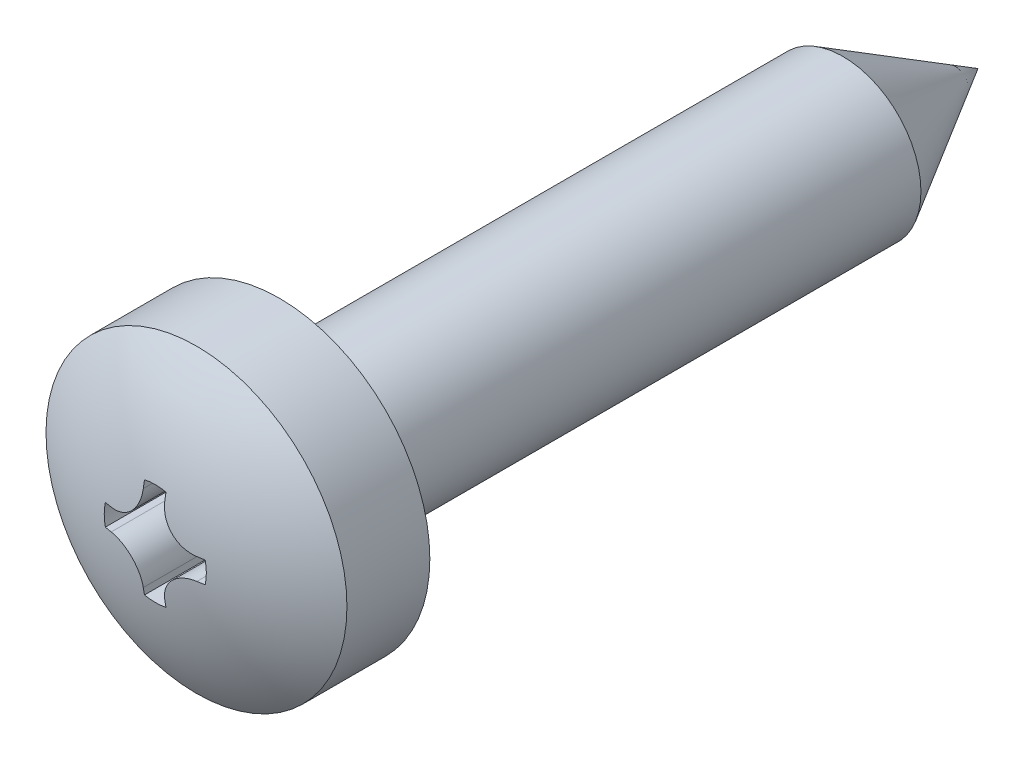
from build123d import *

# Parameters (mm, degrees)
CUT_EXTRUDE_2_DEPTH = 1.2
FILLET_1_R          = 0.1


with BuildPart() as part:
    # 草图8 → Revolve 1380 (revolve)
    with BuildSketch(Plane(origin=(0, 0, 0), x_dir=(0, 0, -1), z_dir=(1, 0, 0))):
        with BuildLine():
            Line((0, 0), (-15.4, 0))
            ThreePointArc((-15.4, 0), (-15.180811394, 1.464186604), (-14.542463035, 2.8))
            Line((-14.542463035, 2.8), (-13, 2.8))
            Line((-13, 2.8), (-13, 1.45))
            Line((-13, 1.45), (-2.511473671, 1.45))
            Line((-2.511473671, 1.45), (0, 0))
        make_face()
    revolve(axis=Axis((0, 0, 11.71), (0, 0, -1)))

    # 草图7 → 切除-拉伸2 (cut)
    with BuildSketch(Plane.XY.offset(15.4)):
        with BuildLine():
            Line((0.2, 0.928708781), (0.2, 0.797500009))
            ThreePointArc((0.2, 0.797500009), (0.375003701, 0.375003701), (0.797500009, 0.2))
            Line((0.797500009, 0.2), (0.928708781, 0.2))
            ThreePointArc((0.928708781, 0.2), (0.95, 0), (0.928708781, -0.2))
            Line((0.928708781, -0.2), (0.797500009, -0.2))
            ThreePointArc((0.797500009, -0.2), (0.375003701, -0.375003701), (0.2, -0.797500009))
            Line((0.2, -0.797500009), (0.2, -0.928708781))
            ThreePointArc((0.2, -0.928708781), (0, -0.95), (-0.2, -0.928708781))
            Line((-0.2, -0.928708781), (-0.2, -0.797500009))
            ThreePointArc((-0.2, -0.797500009), (-0.375003701, -0.375003701), (-0.797500009, -0.2))
            Line((-0.797500009, -0.2), (-0.928708781, -0.2))
            ThreePointArc((-0.928708781, -0.2), (-0.95, 0), (-0.928708781, 0.2))
            Line((-0.928708781, 0.2), (-0.797500009, 0.2))
            ThreePointArc((-0.797500009, 0.2), (-0.375003701, 0.375003701), (-0.2, 0.797500009))
            Line((-0.2, 0.797500009), (-0.2, 0.928708781))
            ThreePointArc((-0.2, 0.928708781), (0, 0.95), (0.2, 0.928708781))
        make_face()
    extrude(amount=-CUT_EXTRUDE_2_DEPTH, mode=Mode.SUBTRACT)

    # 圆角1
    fillet_1_edges = [part.edges().sort_by_distance(p)[0] for p in [
        (0, -1.45, 13),
    ]]
    fillet(fillet_1_edges, radius=FILLET_1_R)


solid = part.part
